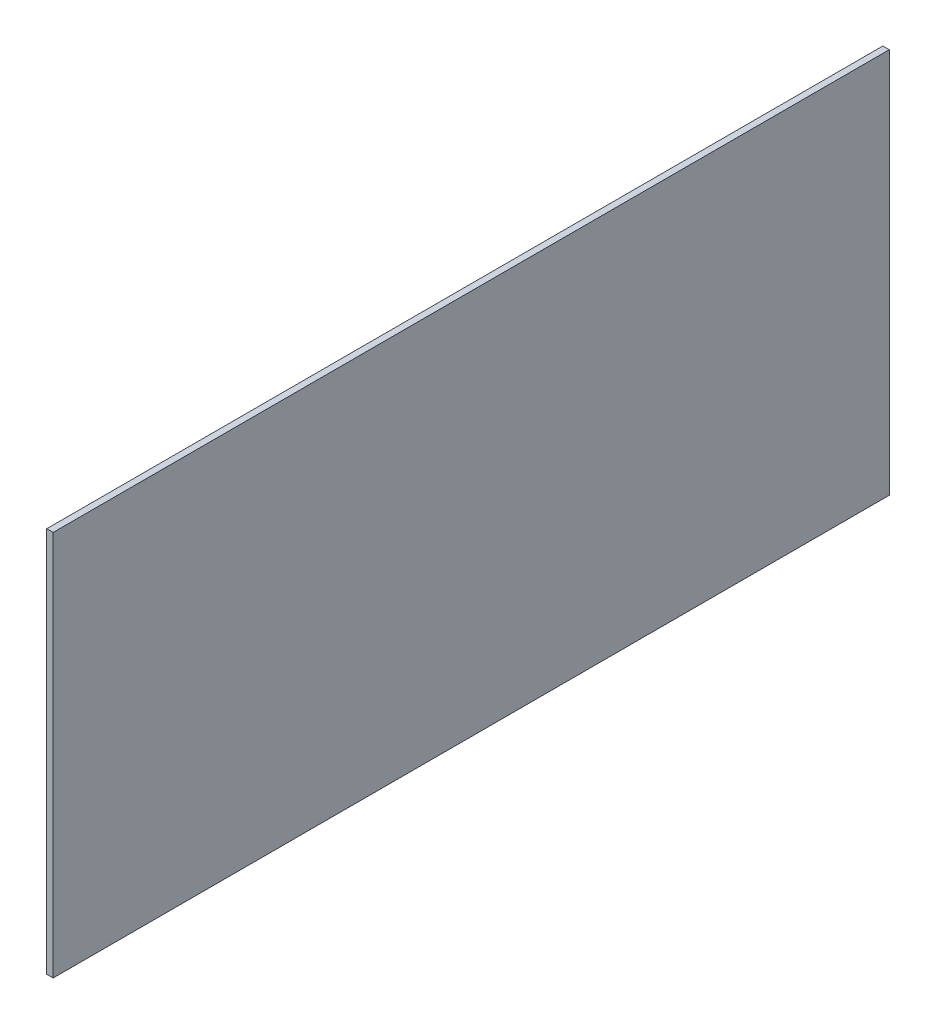
from build123d import *

# Parameters (mm, degrees)
SKETCH1_W           = 130
SKETCH1_H           = 60
BOSS_EXTRUDE1_DEPTH = 1


with BuildPart() as part:
    # Sketch1 → Boss-Extrude1 (new body)
    with BuildSketch(Plane(origin=(0, 0, 0), x_dir=(0, 0, -1), z_dir=(1, 0, 0))):
        with Locations((31.146465375, -20.01894847)):
            Rectangle(SKETCH1_W, SKETCH1_H)
    extrude(amount=BOSS_EXTRUDE1_DEPTH)


solid = part.part
